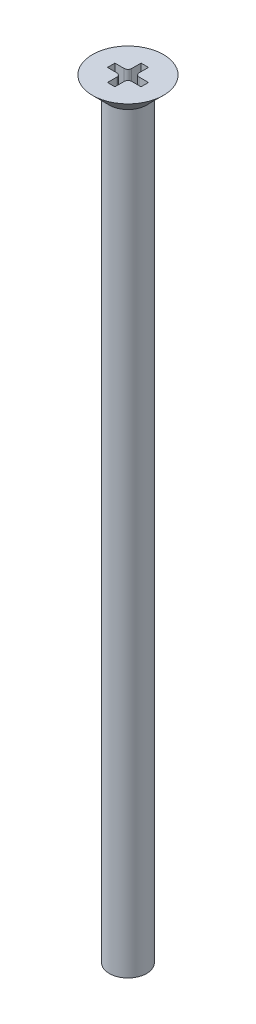
from build123d import *

# Parameters (mm, degrees)
SKETCH2_R           = 1
BOSS_EXTRUDE1_DEPTH = 40
CUT_EXTRUDE1_DEPTH  = 1


with BuildPart() as part:
    # Sketch1 → Revolve1 (revolve)
    with BuildSketch(Plane(origin=(0, 0, 0), x_dir=(0, 0, -1), z_dir=(1, 0, 0))):
        Polygon((0, 0), (-1.9, 0), (-1, -0.9), (-1, -1.2), (0, -1.2), align=None)
    revolve(axis=Axis((0, 0.872326939, 0), (0, -1, 0)))

    # Sketch2 → Boss-Extrude1 (add)
    with BuildSketch(Plane.XZ.offset(1.2)):
        Circle(SKETCH2_R)
    extrude(amount=BOSS_EXTRUDE1_DEPTH)

    # Sketch3 → Cut-Extrude1 (cut)
    with BuildSketch(Plane(origin=(0, 0, 0), x_dir=(1, 0, 0), z_dir=(0, 1, 0))):
        with BuildLine():
            Line((-0.9, -0.2), (-0.4, -0.2))
            ThreePointArc((-0.4, -0.2), (-0.258578644, -0.258578644), (-0.2, -0.4))
            Line((-0.2, -0.4), (-0.2, -0.9))
            Line((-0.2, -0.9), (0.2, -0.9))
            Line((0.2, -0.9), (0.2, -0.4))
            ThreePointArc((0.2, -0.4), (0.258578644, -0.258578644), (0.4, -0.2))
            Line((0.4, -0.2), (0.9, -0.2))
            Line((0.9, -0.2), (0.9, 0.2))
            Line((0.9, 0.2), (0.4, 0.2))
            ThreePointArc((0.4, 0.2), (0.258578644, 0.258578644), (0.2, 0.4))
            Line((0.2, 0.4), (0.2, 0.9))
            Line((0.2, 0.9), (-0.2, 0.9))
            Line((-0.2, 0.9), (-0.2, 0.4))
            ThreePointArc((-0.2, 0.4), (-0.258578644, 0.258578644), (-0.4, 0.2))
            Line((-0.4, 0.2), (-0.9, 0.2))
            Line((-0.9, 0.2), (-0.9, -0.2))
        make_face()
    extrude(amount=-CUT_EXTRUDE1_DEPTH, mode=Mode.SUBTRACT)


solid = part.part
